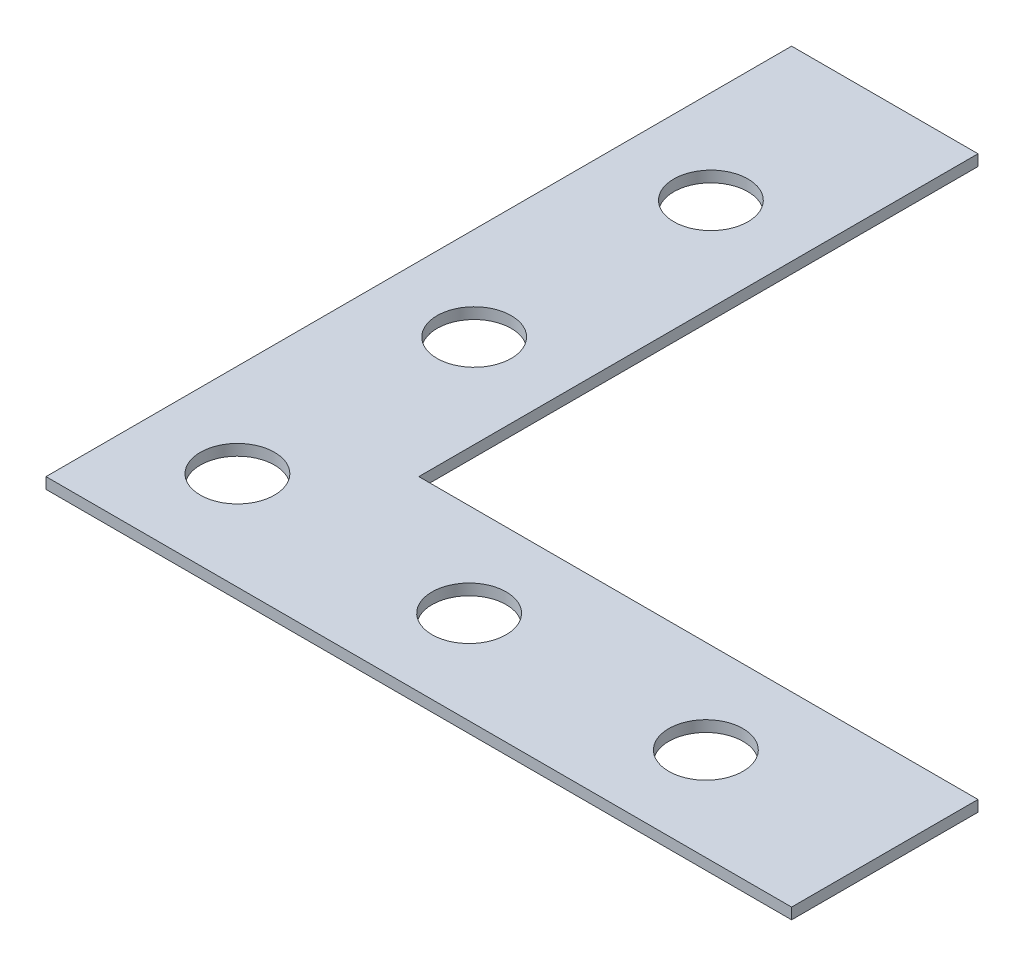
from build123d import *

# Parameters (mm, degrees)
BOSS_EXTRUDE1_DEPTH = 1.19
SKETCH2_R           = 3.97875
SKETCH2_R_2         = 3.98
CUT_EXTRUDE1_DEPTH  = 1.19


with BuildPart() as part:
    # Sketch1 → Boss-Extrude1 (new body)
    with BuildSketch(Plane(origin=(0, 0, 0), x_dir=(1, 0, 0), z_dir=(0, 1, 0))):
        Polygon((0, 0), (80, 0), (80, 20), (20, 20), (20, 80), (0, 80), align=None)
    extrude(amount=BOSS_EXTRUDE1_DEPTH)

    # Sketch2 → Cut-Extrude1 (cut)
    with BuildSketch(Plane(origin=(0, 1.19, 0), x_dir=(1, 0, 0), z_dir=(0, 1, 0))):
        with Locations((10, 61.34)):
            Circle(SKETCH2_R)
        with Locations((10, 35.94)):
            Circle(SKETCH2_R_2)
        with Locations((10, 10.54)):
            Circle(SKETCH2_R_2)
        with Locations((35.4, 10)):
            Circle(SKETCH2_R_2)
        with Locations((60.8, 10)):
            Circle(SKETCH2_R_2)
    extrude(amount=-CUT_EXTRUDE1_DEPTH, mode=Mode.SUBTRACT)


solid = part.part
